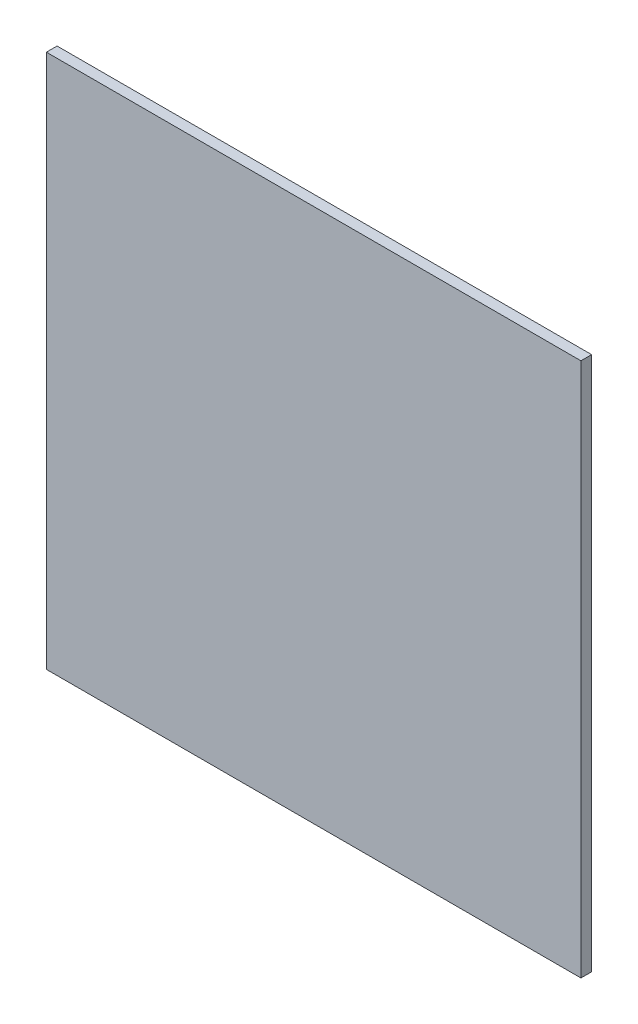
from build123d import *

# Parameters (mm, degrees)
SZKIC1_W                    = 100
SZKIC1_H                    = 100
DODANIE_WYCI_GNI_CIE1_DEPTH = 4


with BuildPart() as part:
    # Szkic1 → Dodanie-wyciągnięcie1 (new body)
    with BuildSketch(Plane.XY):
        with Locations((-50, 50)):
            Rectangle(SZKIC1_W, SZKIC1_H)
        with Locations((50, 50)):
            Rectangle(SZKIC1_W, SZKIC1_H)
        with Locations((50, -50)):
            Rectangle(SZKIC1_W, SZKIC1_H)
        with Locations((-50, -50)):
            Rectangle(SZKIC1_W, SZKIC1_H)
    extrude(amount=DODANIE_WYCI_GNI_CIE1_DEPTH)


solid = part.part
